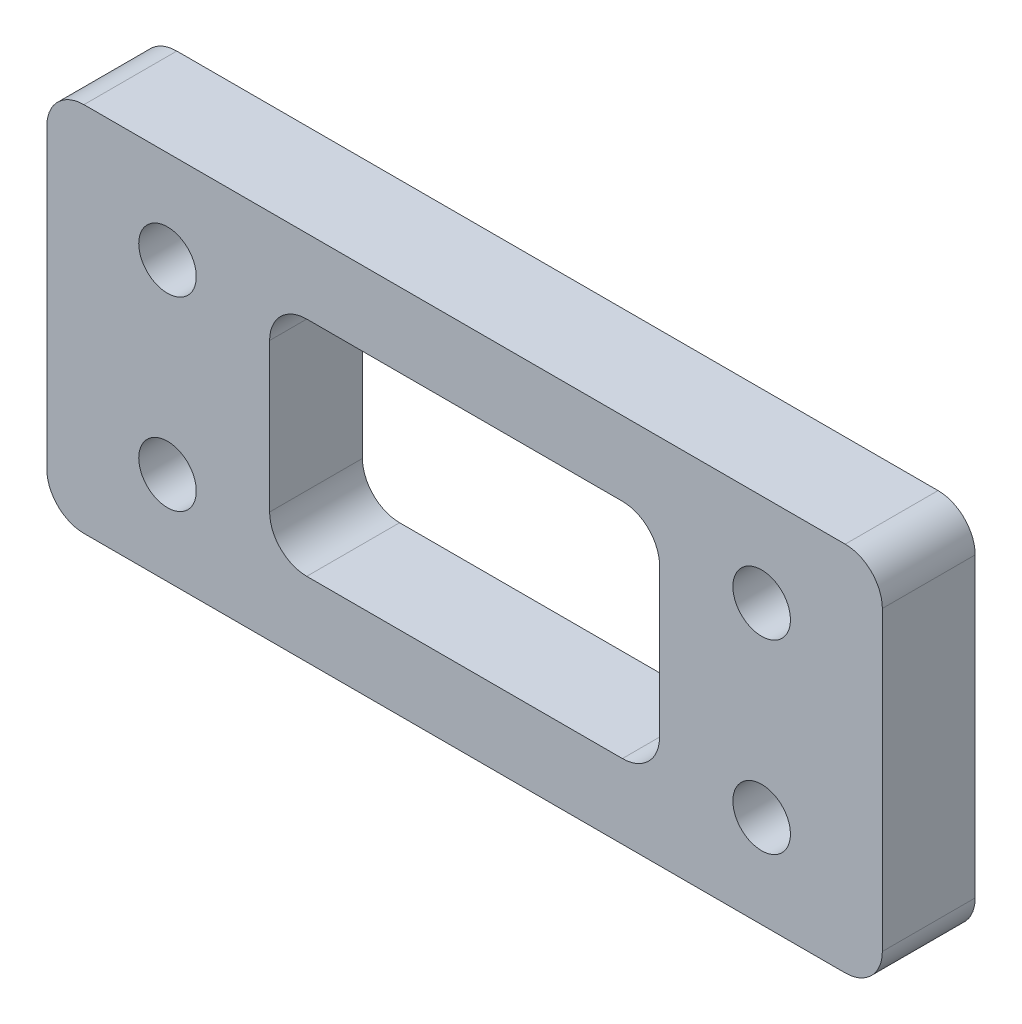
from build123d import *

# Parameters (mm, degrees)
SKETCH_1_W          = 45
SKETCH_1_H          = 20
EXTRUDE_1_DEPTH     = 2.5
SKETCH_3_R          = 1.55
CUT_EXTRUDE_1_DEPTH = 32.5
FILLET_1_R          = 2
SKETCH_4_W          = 21
SKETCH_4_H          = 12
CUT_EXTRUDE_2_DEPTH = 30
FILLET_2_R          = 2


with BuildPart() as part:
    # 草图1 → 凸台-拉伸1 (new body, symmetric)
    with BuildSketch(Plane.XY):
        Rectangle(SKETCH_1_W, SKETCH_1_H)
    extrude(amount=EXTRUDE_1_DEPTH, both=True)

    # 草图3 → 切除-拉伸1 (cut, symmetric)
    with BuildSketch(Plane.XY.offset(2.5)):
        with Locations((16, 5)):
            Circle(SKETCH_3_R)
        with Locations((-16, 5)):
            Circle(SKETCH_3_R)
        with Locations((-16, -5)):
            Circle(SKETCH_3_R)
        with Locations((16, -5)):
            Circle(SKETCH_3_R)
    extrude(amount=CUT_EXTRUDE_1_DEPTH, both=True, mode=Mode.SUBTRACT)

    # 圆角1
    fillet_1_edges = [part.edges().sort_by_distance(p)[0] for p in [
        (22.5, -10, 0),
        (-22.5, -10, 0),
        (-22.5, 10, 0),
        (22.5, 10, 0),
    ]]
    fillet(fillet_1_edges, radius=FILLET_1_R)

    # 草图4 → 切除-拉伸2 (cut)
    with BuildSketch(Plane.XY.offset(2.5)):
        Rectangle(SKETCH_4_W, SKETCH_4_H)
    extrude(amount=-CUT_EXTRUDE_2_DEPTH, mode=Mode.SUBTRACT)

    # 圆角2
    fillet_2_edges = [part.edges().sort_by_distance(p)[0] for p in [
        (10.5, 6, 0),
        (10.5, -6, 0),
        (-10.5, -6, 0),
        (-10.5, 6, 0),
    ]]
    fillet(fillet_2_edges, radius=FILLET_2_R)


solid = part.part
